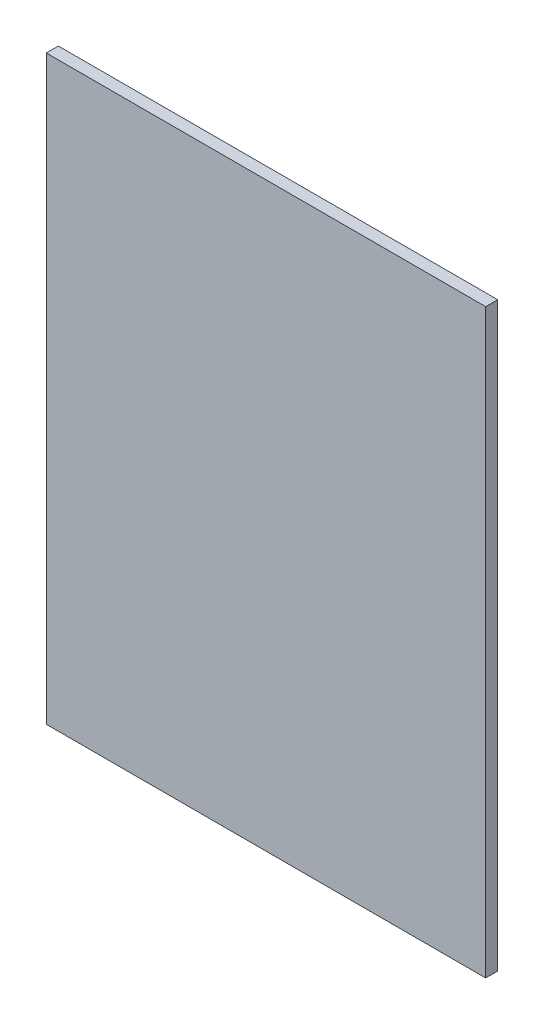
from build123d import *

# Parameters (mm, degrees)
SKETCH1_W           = 109.6
SKETCH1_H           = 145
BOSS_EXTRUDE1_DEPTH = 3


with BuildPart() as part:
    # Sketch1 → Boss-Extrude1 (new body)
    with BuildSketch(Plane.XY):
        with Locations((54.8, -72.5)):
            Rectangle(SKETCH1_W, SKETCH1_H)
    extrude(amount=BOSS_EXTRUDE1_DEPTH)


solid = part.part
